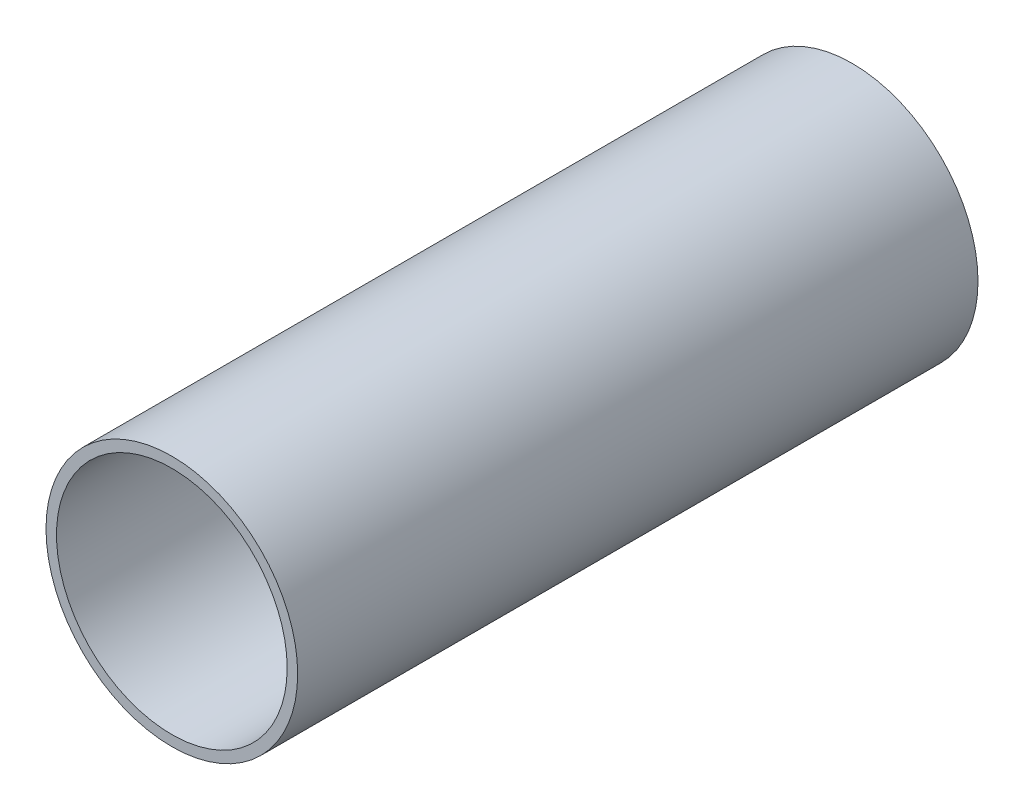
from build123d import *

# Parameters (mm, degrees)
SKETCH1_R           = 76.2
SKETCH1_R_2         = 69.85
BOSS_EXTRUDE1_DEPTH = 412


with BuildPart() as part:
    # Sketch1 → Boss-Extrude1 (new body)
    with BuildSketch(Plane.XY):
        Circle(SKETCH1_R)
        Circle(SKETCH1_R_2, mode=Mode.SUBTRACT)
    extrude(amount=BOSS_EXTRUDE1_DEPTH)


solid = part.part
